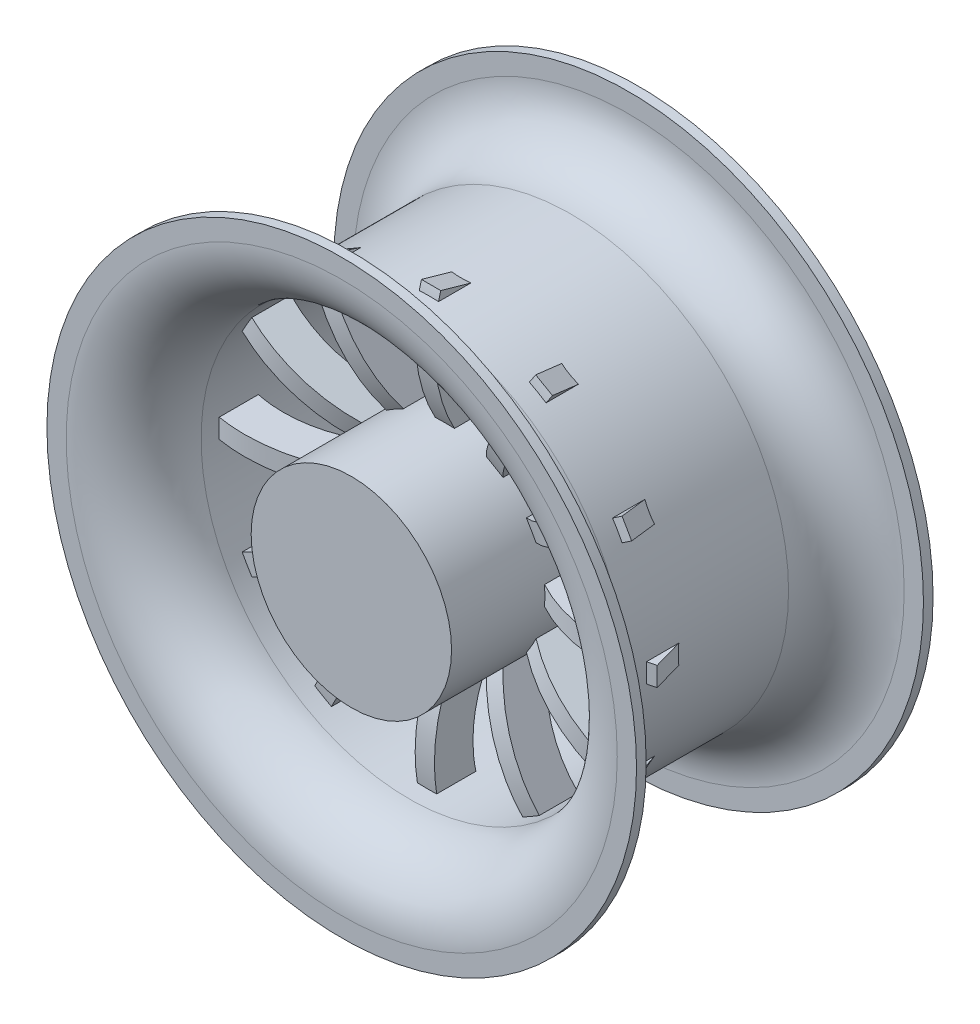
from build123d import *

# Parameters (mm, degrees)
CROQUIS1_R              = 5.2
SALIENTE_EXTRUIR1_DEPTH = 17.9
SALIENTE_EXTRUIR2_DEPTH = 0.5
MATRIZC1_COUNT          = 12
CORTAR_EXTRUIR1_DEPTH   = 7.9
CROQUIS5_R              = 5.2
CORTAR_EXTRUIR2_DEPTH   = 6
DAR_ESPESOR1_T1         = 0.5


with BuildPart() as part:
    # Croquis1 → Saliente-Extruir1 (new body)
    with BuildSketch(Plane.XY):
        with Locations(Location((0, 0, 0), (0, 0, 180))):
            Circle(CROQUIS1_R)
    extrude(amount=SALIENTE_EXTRUIR1_DEPTH)

    # Croquis3 → Saliente-Extruir2 (add, symmetric)
    with BuildSketch(Plane(origin=(0, 0, 0), x_dir=(0, 0, -1), z_dir=(1, 0, 0))):
        with BuildLine():
            Line((-9.180931253, 0.167070732), (-11.152821078, -0.167070732))
            add(Edge.make_bspline(
                [(-11.152821078, -0.167070732), (-11.178056732, -0.018145994), (-11.198836983, 0.293342282), (-11.176359609, 0.845383623), (-11.104039677, 1.532143797), (-11.068581377, 2.162782208), (-11.098655973, 2.566976179), (-11.147376818, 2.796714035), (-11.213560733, 2.941188622), (-11.259501688, 3.009055487), (-11.490121796, 3.222436192), (-11.952672763, 3.649075978), (-12.433006614, 4.20681822), (-12.93508403, 4.944649607), (-13.342092081, 5.727868004), (-13.768002407, 6.822420414), (-14.08214955, 8.258219316), (-14.120186408, 10.018172843), (-13.919758847, 11.171451478), (-13.761933161, 11.731000971)],
                knots=[0, 0, 0, 0, 0.03125, 0.0625, 0.125, 0.1875, 0.21875, 0.25, 0.28125, 0.3125, 0.34375, 0.375, 0.4375, 0.5, 0.5625, 0.625, 0.75, 0.875, 1, 1, 1, 1], degree=3))
            Line((-13.761933161, 11.731000971), (-11.837037435, 11.188067786))
            add(Edge.make_bspline(
                [(-9.180931253, 0.167070732), (-9.183938661, 0.184818536), (-9.187043235, 0.210996098), (-9.193791536, 0.34112998), (-9.18621694, 0.571378818), (-9.15622286, 0.932526226), (-9.104277385, 1.489150949), (-9.06304316, 2.127557623), (-9.108304054, 2.817389333), (-9.217633288, 3.358595189), (-9.435664372, 3.913657386), (-9.841584551, 4.439830264), (-10.190639862, 4.739917651), (-10.486034041, 5.019256561), (-10.848625537, 5.432432454), (-11.211090301, 5.96856272), (-11.516377763, 6.553544849), (-11.839218682, 7.383146784), (-12.083836499, 8.493469208), (-12.112653005, 9.871550224), (-11.958760659, 10.756514659), (-11.837037435, 11.188067786)],
                knots=[0, 0, 0, 0, 0.015625, 0.03125, 0.0625, 0.09375, 0.125, 0.1875, 0.21875, 0.25, 0.28125, 0.3125, 0.34375, 0.375, 0.4375, 0.5, 0.5625, 0.625, 0.75, 0.875, 1, 1, 1, 1], degree=3))
        make_face()
    saliente_extruir2 = extrude(amount=SALIENTE_EXTRUIR2_DEPTH, both=True)

    # MatrizC1: Saliente-Extruir2 ×12 about axis
    matrizc1_axis = Axis((0, 0, 17.9), (0, 0, 1))
    for i in range(1, MATRIZC1_COUNT):
        add(saliente_extruir2.rotate(matrizc1_axis, i * 360 / MATRIZC1_COUNT))

    # Croquis4 → Cortar-Extruir1 (cut)
    with BuildSketch(Plane(origin=(0, 0, 0), x_dir=(-1, 0, 0), z_dir=(0, 0, -1))):
        with BuildLine():
            Line((1.8, 0), (-1.8, 0))
            Line((-1.8, 0), (-1.8, -2.01246118))
            ThreePointArc((-1.8, -2.01246118), (0, -2.7), (1.8, -2.01246118))
            Line((1.8, -2.01246118), (1.8, 0))
        make_face()
        with BuildLine():
            Line((-1.8, 2.01246118), (-1.8, 0))
            Line((-1.8, 0), (1.8, 0))
            Line((1.8, 0), (1.8, 2.01246118))
            ThreePointArc((1.8, 2.01246118), (0, 2.7), (-1.8, 2.01246118))
        make_face()
    extrude(amount=-CORTAR_EXTRUIR1_DEPTH, mode=Mode.SUBTRACT)

    # Croquis5 → Cortar-Extruir2 (cut)
    with BuildSketch(Plane(origin=(0, 0, 0), x_dir=(-1, 0, 0), z_dir=(0, 0, -1))):
        Circle(CROQUIS5_R)
        with BuildLine():
            Line((-1.8, -2.01246118), (-1.8, 2.01246118))
            ThreePointArc((-1.8, 2.01246118), (0, 2.7), (1.8, 2.01246118))
            Line((1.8, 2.01246118), (1.8, -2.01246118))
            ThreePointArc((1.8, -2.01246118), (0, -2.7), (-1.8, -2.01246118))
        make_face(mode=Mode.SUBTRACT)
    extrude(amount=-CORTAR_EXTRUIR2_DEPTH, mode=Mode.SUBTRACT)

    # Superficie-Revoluci_n1: a surface, the sketch's curves turned about an axis
    with BuildLine(Plane(origin=(0, 0, 0), x_dir=(0, 0, -1), z_dir=(1, 0, 0)), mode=Mode.PRIVATE) as superficie_revoluci_n1_1_path:
        Line((-17.9, 15.3), (-17.9, 14.3))
        ThreePointArc((-17.9, 14.3), (-17.021320344, 12.178679656), (-14.9, 11.3))
        Line((-14.9, 11.3), (-6.51, 11.3))
        ThreePointArc((-6.51, 11.3), (-4.388679656, 12.178679656), (-3.51, 14.3))
        Line((-3.51, 14.3), (-3.51, 15.3))
    superficie_revoluci_n1_1 = Shell.revolve(superficie_revoluci_n1_1_path.wire(), 360, Axis((0, 0, 0), (0, 0, 1)))
    add(Solid.thicken(superficie_revoluci_n1_1, DAR_ESPESOR1_T1))


solid = part.part
